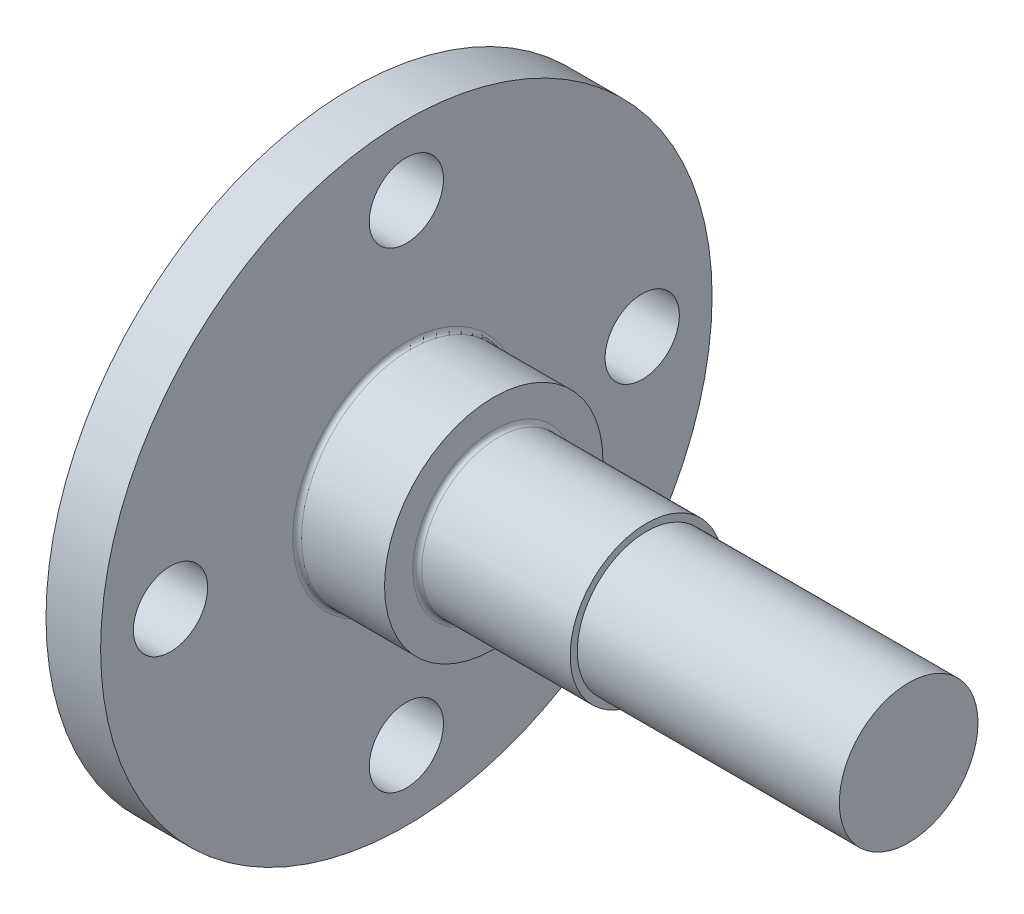
from build123d import *

# Parameters (mm, degrees)
SKETCH1_W                = 120
SKETCH1_H                = 34
BOSS_EXTRUDE1_DEPTH      = 5
BOSS_EXTRUDE2_DEPTH      = 4
SKETCH3_R                = 3.5
BOSS_EXTRUDE3_DEPTH      = 19
SKETCH4_R                = 3.5
SKETCH4_R_2              = 3.175
CUT_EXTRUDE1_DEPTH       = 12
FILLET1_R                = 0.2
SKETCH5_W                = 120
SKETCH5_H                = 34
SKETCH5_R                = 14
CUT_EXTRUDE2_DEPTH       = 6
M3_CLEARANCE_HOLE1_D     = 3.4
M3_CLEARANCE_HOLE1_DEPTH = 15
M3_CLEARANCE_HOLE1_TIP   = 1.021463052
SKETCH9_W                = 2.5
SKETCH9_H                = 28
CUT_EXTRUDE6_DEPTH       = 29


with BuildPart() as part:
    # Sketch1 → Boss-Extrude1 (new body)
    with BuildSketch(Plane(origin=(0, 0, 0), x_dir=(0, 0, -1), z_dir=(1, 0, 0))):
        with Locations((-60, 17)):
            Rectangle(SKETCH1_W, SKETCH1_H)
    extrude(amount=BOSS_EXTRUDE1_DEPTH)

    # Sketch2 → Boss-Extrude2 (add)
    with BuildSketch(Plane(origin=(5, 0, 0), x_dir=(0, 0, -1), z_dir=(1, 0, 0))):
        with BuildLine():
            ThreePointArc((-55, 17), (-56.464466094, 20.535533906), (-60, 22))
            Line((-60, 22), (-60, 12))
            ThreePointArc((-60, 12), (-56.464466094, 13.464466094), (-55, 17))
        make_face()
        with BuildLine():
            Line((-60, 12), (-60, 22))
            ThreePointArc((-60, 22), (-65, 17), (-60, 12))
        make_face()
    extrude(amount=BOSS_EXTRUDE2_DEPTH)

    # Sketch3 → Boss-Extrude3 (add)
    with BuildSketch(Plane(origin=(9, 0, 0), x_dir=(0, 0, -1), z_dir=(1, 0, 0))):
        with Locations((-60, 17)):
            Circle(SKETCH3_R)
    extrude(amount=BOSS_EXTRUDE3_DEPTH)

    # Sketch4 → Cut-Extrude1 (cut)
    with BuildSketch(Plane(origin=(28, 0, 0), x_dir=(0, 0, -1), z_dir=(1, 0, 0))):
        with Locations((-60, 17)):
            Circle(SKETCH4_R)
        with Locations((-60, 17)):
            Circle(SKETCH4_R_2, mode=Mode.SUBTRACT)
    extrude(amount=-CUT_EXTRUDE1_DEPTH, mode=Mode.SUBTRACT)

    # Fillet1
    fillet1_edges = [part.edges().sort_by_distance(p)[0] for p in [
        (5, 12, 60),
        (9, 17, 63.5),
    ]]
    fillet(fillet1_edges, radius=FILLET1_R)

    # Sketch5 → Cut-Extrude2 (cut, through all)
    with BuildSketch(Plane(origin=(5, 0, 0), x_dir=(0, 0, -1), z_dir=(1, 0, 0))):
        with Locations((-60, 17)):
            Rectangle(SKETCH5_W, SKETCH5_H)
        with Locations((-60, 17)):
            Circle(SKETCH5_R, mode=Mode.SUBTRACT)
    extrude(amount=-CUT_EXTRUDE2_DEPTH, mode=Mode.SUBTRACT)

    # M3 Clearance Hole1
    with Locations(Plane(origin=(5, 0, 0), x_dir=(0, 0, -1), z_dir=(1, 0, 0))):
        with Locations((-60, 27.8), (-49.2, 17), (-60, 6.2), (-70.8, 17)):
            Hole(M3_CLEARANCE_HOLE1_D / 2, depth=M3_CLEARANCE_HOLE1_DEPTH)
            with Locations((0, 0, -(M3_CLEARANCE_HOLE1_DEPTH + M3_CLEARANCE_HOLE1_TIP / 2))):  # 118° drill point
                Cone(0, M3_CLEARANCE_HOLE1_D / 2, M3_CLEARANCE_HOLE1_TIP, mode=Mode.SUBTRACT)

    # Sketch9 → Cut-Extrude6 (cut, through all)
    with BuildSketch(Plane(origin=(0, 0, 46), x_dir=(-1, 0, 0), z_dir=(0, 0, -1))):
        with Locations((-1.25, 17)):
            Rectangle(SKETCH9_W, SKETCH9_H)
    extrude(amount=-CUT_EXTRUDE6_DEPTH, mode=Mode.SUBTRACT)


solid = part.part
